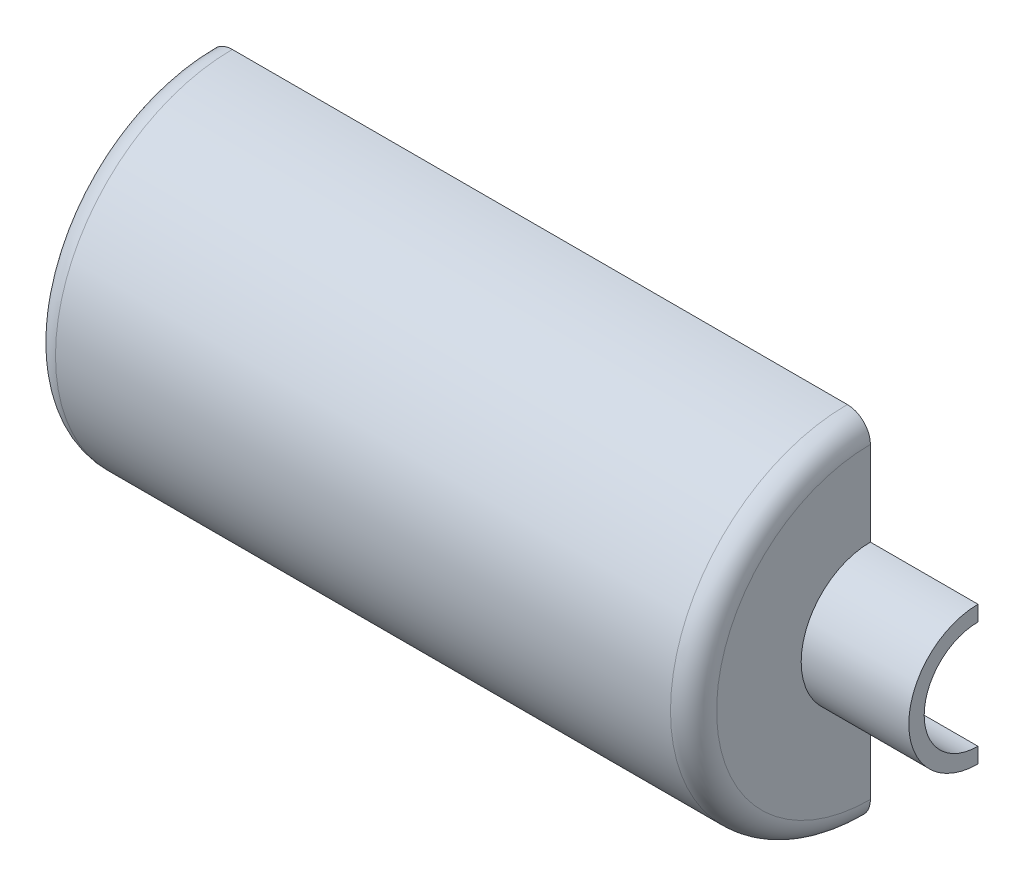
from build123d import *

# Parameters (mm, degrees)
REVOLVE1_ANGLE = 180


with BuildPart() as part:
    # Sketch1 → Revolve1 (revolve)
    with BuildSketch(Plane.XY):
        with BuildLine():
            Line((-215, 0), (-215, 100))
            ThreePointArc((-215, 100), (-210.606601718, 110.606601718), (-200, 115))
            Line((-200, 115), (200, 115))
            ThreePointArc((200, 115), (210.606601718, 110.606601718), (215, 100))
            Line((215, 100), (215, 45))
            Line((215, 45), (285, 45))
            Line((285, 45), (285, 35))
            Line((285, 35), (200, 35))
            Line((200, 35), (200, 92.5))
            ThreePointArc((200, 92.5), (197.803300859, 97.803300859), (192.5, 100))
            Line((192.5, 100), (-192.5, 100))
            ThreePointArc((-192.5, 100), (-197.803300859, 97.803300859), (-200, 92.5))
            Line((-200, 92.5), (-200, 0))
            Line((-200, 0), (-215, 0))
        make_face()
    revolve(axis=Axis((0, 0, 0), (1, 0, 0)), revolution_arc=REVOLVE1_ANGLE)


solid = part.part
